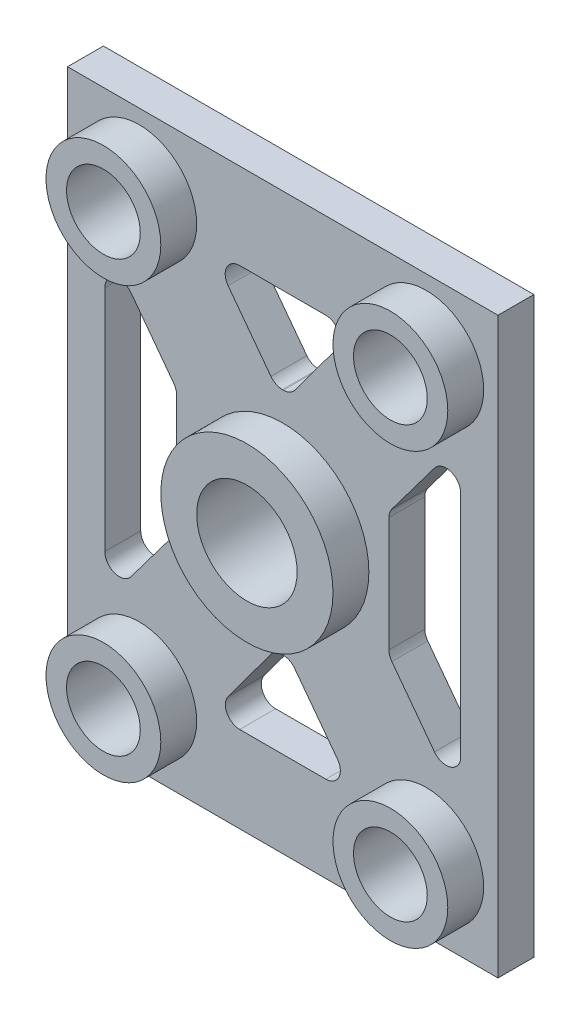
from build123d import *

# Parameters (mm, degrees)
SKETCH1_W                           = 38.1
SKETCH1_H                           = 50.8
SKETCH1_R                           = 3.2639
SKETCH1_R_2                         = 4.445
BASE_EXTRUDE_DEPTH                  = 3.175
SKETCH2_R                           = 7.62
SKETCH2_R_2                         = 4.445
SKETCH2_R_3                         = 5.08
SKETCH2_R_4                         = 3.2639
RAISER_DEPTH                        = 3.175
WEIGHT_REDUCTION_SCREW_ACCESS_DEPTH = 4.175


with BuildPart() as part:
    # Sketch1 → Base Extrude (new body)
    with BuildSketch(Plane.XY):
        with Locations((19.05, -25.4)):
            Rectangle(SKETCH1_W, SKETCH1_H)
        with Locations((6.35, -6.35)):
            Circle(SKETCH1_R, mode=Mode.SUBTRACT)
        with Locations((6.35, -44.45)):
            Circle(SKETCH1_R, mode=Mode.SUBTRACT)
        with Locations((31.75, -44.45)):
            Circle(SKETCH1_R, mode=Mode.SUBTRACT)
        with Locations((31.75, -6.35)):
            Circle(SKETCH1_R, mode=Mode.SUBTRACT)
        with Locations((19.05, -25.4)):
            Circle(SKETCH1_R_2, mode=Mode.SUBTRACT)
    extrude(amount=BASE_EXTRUDE_DEPTH)

    # Sketch2 → Raiser (add)
    with BuildSketch(Plane.XY.offset(3.175)):
        with Locations((19.05, -25.4)):
            Circle(SKETCH2_R)
        with Locations((19.05, -25.4)):
            Circle(SKETCH2_R_2, mode=Mode.SUBTRACT)
        with Locations((6.35, -6.35)):
            Circle(SKETCH2_R_3)
        with Locations((6.35, -6.35)):
            Circle(SKETCH2_R_4, mode=Mode.SUBTRACT)
        with Locations((31.75, -6.35)):
            Circle(SKETCH2_R_3)
        with Locations((31.75, -6.35)):
            Circle(SKETCH2_R_4, mode=Mode.SUBTRACT)
        with Locations((6.35, -44.45)):
            Circle(SKETCH2_R_3)
        with Locations((6.35, -44.45)):
            Circle(SKETCH2_R_4, mode=Mode.SUBTRACT)
        with Locations((31.75, -44.45)):
            Circle(SKETCH2_R_3)
        with Locations((31.75, -44.45)):
            Circle(SKETCH2_R_4, mode=Mode.SUBTRACT)
    extrude(amount=RAISER_DEPTH)

    # Sketch3 → Weight Reduction - screw access (cut, through all)
    with BuildSketch(Plane.XY.offset(3.175)):
        with BuildLine():
            Line((3.302, -15.289677034), (3.302, -35.510322966))
            ThreePointArc((3.302, -35.510322966), (4.181713329, -36.730860012), (5.617806221, -36.282258372))
            Line((5.617806221, -36.282258372), (9.394688198, -31.246415736))
            ThreePointArc((9.394688198, -31.246415736), (9.585978035, -30.881326012), (9.652, -30.47448033))
            Line((9.652, -30.47448033), (9.652, -20.32551967))
            ThreePointArc((9.652, -20.32551967), (9.585978035, -19.918673988), (9.394688198, -19.553584264))
            Line((9.394688198, -19.553584264), (5.617806221, -14.517741628))
            ThreePointArc((5.617806221, -14.517741628), (4.181713329, -14.069139988), (3.302, -15.289677034))
        make_face()
        with BuildLine():
            Line((15.24, -7.62), (22.86, -7.62))
            ThreePointArc((22.86, -7.62), (23.993921047, -8.318053273), (23.881326665, -9.644845576))
            Line((23.881326665, -9.644845576), (20.126783029, -14.724845576))
            ThreePointArc((20.126783029, -14.724845576), (19.677403092, -15.103921047), (19.105456364, -15.24))
            Line((19.105456364, -15.24), (19.016881977, -15.24))
            ThreePointArc((19.016881977, -15.24), (18.448920711, -15.105922533), (18.000881977, -14.732))
            Line((18.000881977, -14.732), (14.210752791, -9.678494418))
            ThreePointArc((14.210752791, -9.678494418), (14.089266637, -8.33119233), (15.24, -7.62))
        make_face()
        with BuildLine():
            Line((14.218673335, -41.155154424), (17.973216971, -36.075154424))
            ThreePointArc((17.973216971, -36.075154424), (18.422596908, -35.696078953), (18.994543636, -35.56))
            Line((18.994543636, -35.56), (19.083118023, -35.56))
            ThreePointArc((19.083118023, -35.56), (19.651079289, -35.694077467), (20.099118023, -36.068))
            Line((20.099118023, -36.068), (23.889247209, -41.121505582))
            ThreePointArc((23.889247209, -41.121505582), (24.010733363, -42.46880767), (22.86, -43.18))
            Line((22.86, -43.18), (15.24, -43.18))
            ThreePointArc((15.24, -43.18), (14.106078953, -42.481946727), (14.218673335, -41.155154424))
        make_face()
        with BuildLine():
            Line((28.705311802, -31.246415736), (32.482193779, -36.282258372))
            ThreePointArc((32.482193779, -36.282258372), (33.918286671, -36.730860012), (34.798, -35.510322966))
            Line((34.798, -35.510322966), (34.798, -15.289677034))
            ThreePointArc((34.798, -15.289677034), (33.918286671, -14.069139988), (32.482193779, -14.517741628))
            Line((32.482193779, -14.517741628), (28.705311802, -19.553584264))
            ThreePointArc((28.705311802, -19.553584264), (28.514021965, -19.918673988), (28.448, -20.32551967))
            Line((28.448, -20.32551967), (28.448, -30.47448033))
            ThreePointArc((28.448, -30.47448033), (28.514021965, -30.881326012), (28.705311802, -31.246415736))
        make_face()
    extrude(amount=-WEIGHT_REDUCTION_SCREW_ACCESS_DEPTH, mode=Mode.SUBTRACT)


solid = part.part
